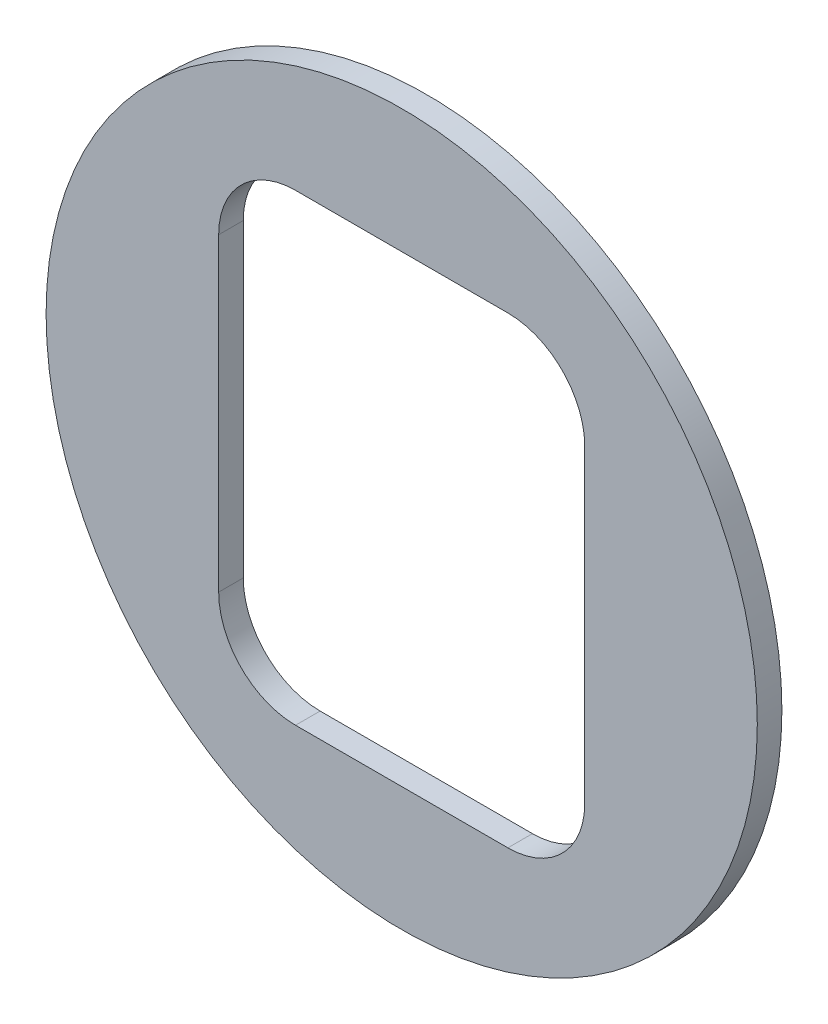
from build123d import *

# Parameters (mm, degrees)
SKETCH1_R      = 22.0345
SKETCH1_W      = 22.6822
SKETCH1_H      = 28.702
EXTRUDE1_DEPTH = 1.524
FILLET1_R      = 4.7625


with BuildPart() as part:
    # Sketch1 → Extrude1 (new body)
    with BuildSketch(Plane.XY):
        Circle(SKETCH1_R)
        Rectangle(SKETCH1_W, SKETCH1_H, mode=Mode.SUBTRACT)
    extrude(amount=EXTRUDE1_DEPTH)

    # Fillet1
    fillet1_edges = [part.edges().sort_by_distance(p)[0] for p in [
        (-11.3411, 14.351, 0.762),
        (-11.3411, -14.351, 0.762),
        (11.3411, -14.351, 0.762),
        (11.3411, 14.351, 0.762),
    ]]
    fillet(fillet1_edges, radius=FILLET1_R)


solid = part.part
